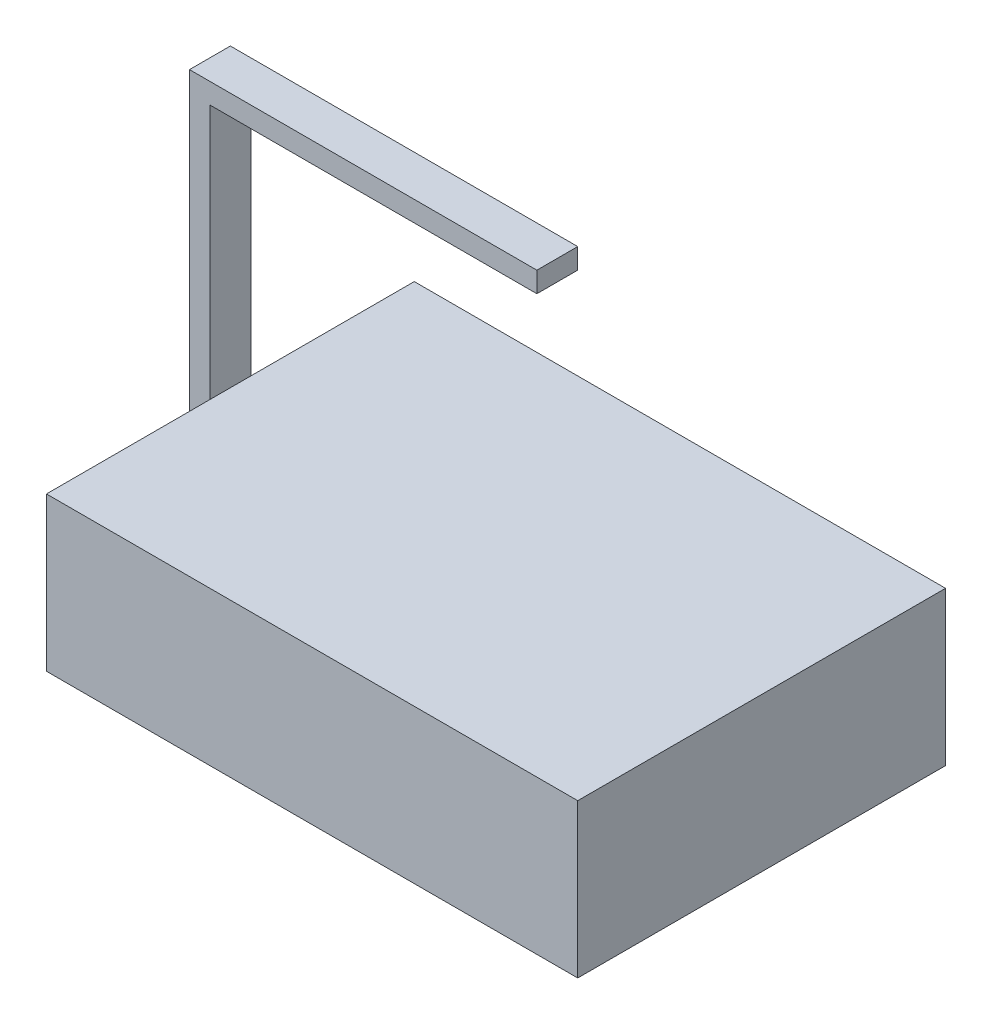
from build123d import *

# Parameters (mm, degrees)
SKETCH1_W           = 130
SKETCH1_H           = 90
BOSS_EXTRUDE1_DEPTH = 37.58
SKETCH2_W           = 10
SKETCH2_H           = 100
BOSS_EXTRUDE2_DEPTH = 5
SKETCH3_W           = 85
SKETCH3_H           = 10
BOSS_EXTRUDE3_DEPTH = 5


with BuildPart() as part:
    # Sketch1 → Boss-Extrude1 (new body)
    with BuildSketch(Plane(origin=(0, 0, 0), x_dir=(1, 0, 0), z_dir=(0, 1, 0))):
        with Locations((65, -45)):
            Rectangle(SKETCH1_W, SKETCH1_H)
    extrude(amount=BOSS_EXTRUDE1_DEPTH)

    # Sketch2 → Boss-Extrude2 (add)
    with BuildSketch(Plane.ZY):
        with Locations((45, 50)):
            Rectangle(SKETCH2_W, SKETCH2_H)
    extrude(amount=BOSS_EXTRUDE2_DEPTH)

    # Sketch3 → Boss-Extrude3 (add)
    with BuildSketch(Plane(origin=(0, 100, 0), x_dir=(1, 0, 0), z_dir=(0, 1, 0))):
        with Locations((37.5, -45)):
            Rectangle(SKETCH3_W, SKETCH3_H)
    extrude(amount=BOSS_EXTRUDE3_DEPTH)


solid = part.part
